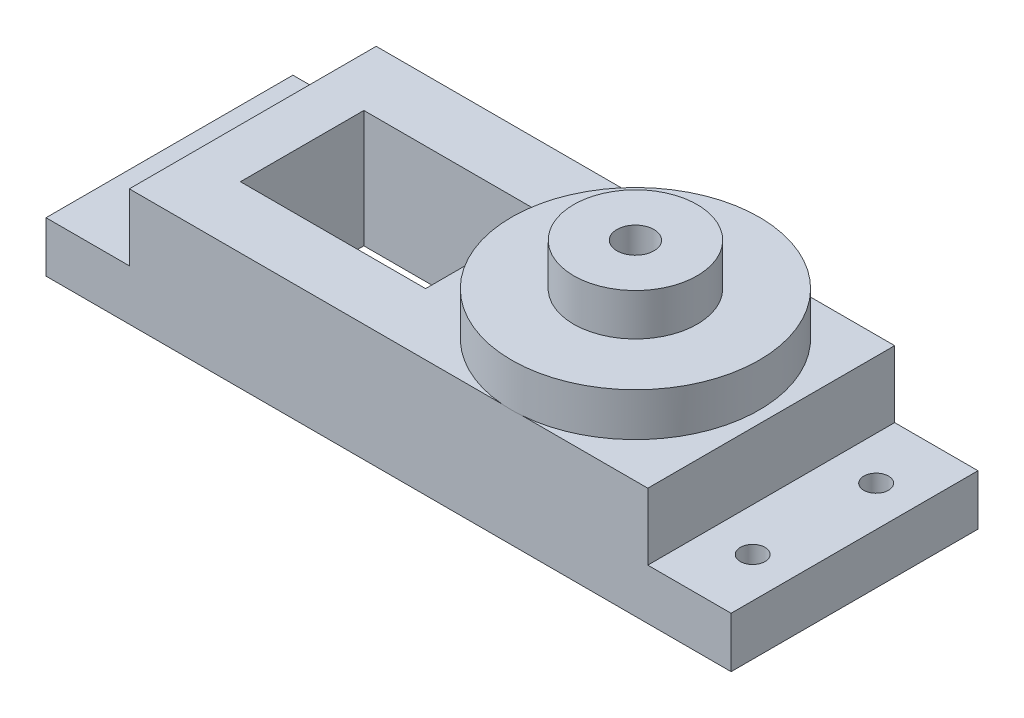
from build123d import *

# Parameters (mm, degrees)
CROQUIS1_W              = 55.5
CROQUIS1_H              = 20
CROQUIS1_R              = 1.000000224
CROQUIS1_R_2            = 1.000000066
CROQUIS1_R_3            = 1.500000028
CROQUIS1_R_4            = 0.999999891
CROQUIS1_R_5            = 0.999999587
CROQUIS1_W_2            = 15
CROQUIS1_H_2            = 10
SALIENTE_EXTRUIR1_DEPTH = 4.1
CROQUIS2_W              = 42
CROQUIS2_H              = 20
CROQUIS2_R              = 1.500000028
CROQUIS2_W_2            = 15
CROQUIS2_H_2            = 10
SALIENTE_EXTRUIR2_DEPTH = 5.4
CROQUIS3_R              = 10.033223334
CROQUIS3_R_2            = 1.500000028
SALIENTE_EXTRUIR3_DEPTH = 3.5
CROQUIS4_R              = 5
CROQUIS4_R_2            = 1.500000028
SALIENTE_EXTRUIR4_DEPTH = 3.4


with BuildPart() as part:
    # Croquis1 → Saliente-Extruir1 (new body)
    with BuildSketch(Plane(origin=(0, 0, 0), x_dir=(1, 0, 0), z_dir=(0, 1, 0))):
        with Locations((-0.49546198, -0.123865495)):
            Rectangle(CROQUIS1_W, CROQUIS1_H)
        with Locations((-24.995460911, 4.876134086)):
            Circle(CROQUIS1_R, mode=Mode.SUBTRACT)
        with Locations((-24.995461734, -5.123865495)):
            Circle(CROQUIS1_R_2, mode=Mode.SUBTRACT)
        with Locations((9.504538064, -0.123865505)):
            Circle(CROQUIS1_R_3, mode=Mode.SUBTRACT)
        with Locations((24.004538739, 4.876134747)):
            Circle(CROQUIS1_R_4, mode=Mode.SUBTRACT)
        with Locations((24.004537606, -5.123865416)):
            Circle(CROQUIS1_R_5, mode=Mode.SUBTRACT)
        with Locations((-9.99546198, -0.123865495)):
            Rectangle(CROQUIS1_W_2, CROQUIS1_H_2, mode=Mode.SUBTRACT)
    extrude(amount=SALIENTE_EXTRUIR1_DEPTH)

    # Croquis2 → Saliente-Extruir2 (add)
    with BuildSketch(Plane(origin=(0, 4.1, 0), x_dir=(1, 0, 0), z_dir=(0, 1, 0))):
        with Locations((-0.49546198, -0.123865495)):
            Rectangle(CROQUIS2_W, CROQUIS2_H)
        with Locations((9.504538064, -0.123865505)):
            Circle(CROQUIS2_R, mode=Mode.SUBTRACT)
        with Locations((-9.99546198, -0.123865495)):
            Rectangle(CROQUIS2_W_2, CROQUIS2_H_2, mode=Mode.SUBTRACT)
    extrude(amount=SALIENTE_EXTRUIR2_DEPTH)

    # Croquis3 → Saliente-Extruir3 (add)
    with BuildSketch(Plane(origin=(0, 9.5, 0), x_dir=(1, 0, 0), z_dir=(0, 1, 0))):
        with Locations((9.504538064, -0.123865505)):
            Circle(CROQUIS3_R)
        with Locations((9.504538064, -0.123865505)):
            Circle(CROQUIS3_R_2, mode=Mode.SUBTRACT)
    extrude(amount=SALIENTE_EXTRUIR3_DEPTH)

    # Croquis4 → Saliente-Extruir4 (add)
    with BuildSketch(Plane(origin=(0, 13, 0), x_dir=(1, 0, 0), z_dir=(0, 1, 0))):
        with Locations((9.504538064, -0.123865505)):
            Circle(CROQUIS4_R)
        with Locations((9.504538064, -0.123865505)):
            Circle(CROQUIS4_R_2, mode=Mode.SUBTRACT)
    extrude(amount=SALIENTE_EXTRUIR4_DEPTH)


solid = part.part
